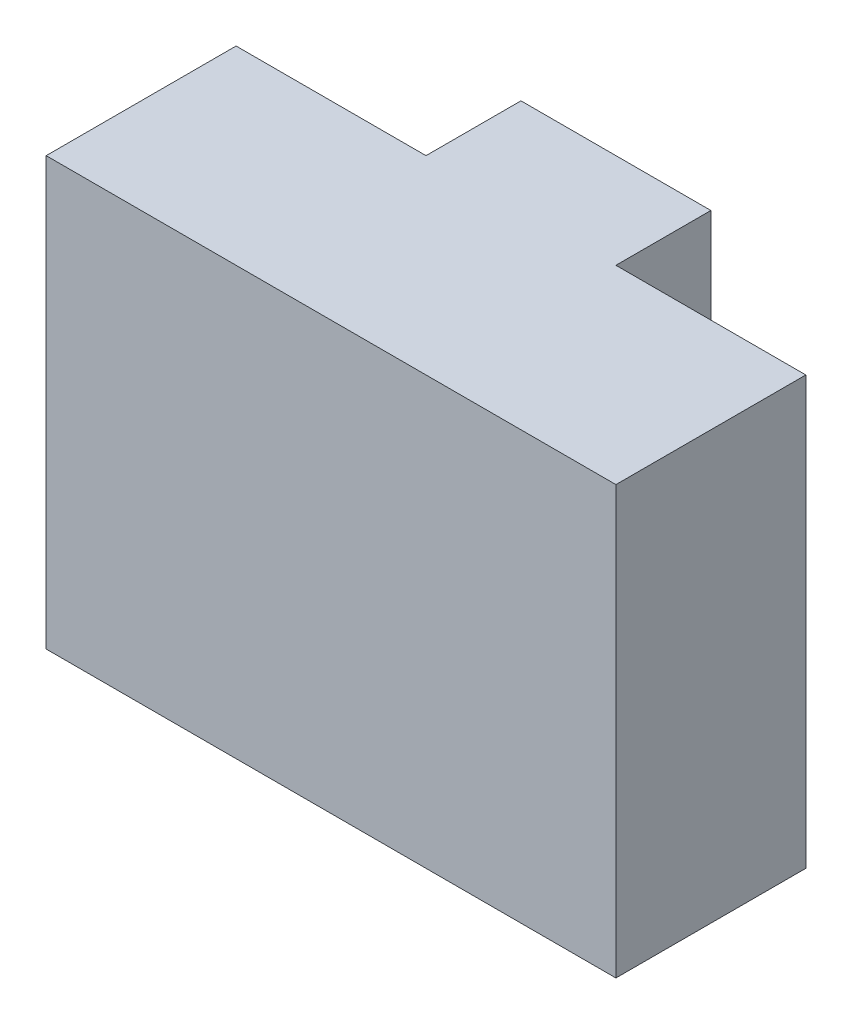
from build123d import *

# Parameters (mm, degrees)
BOSS_EXTRUDE1_DEPTH = 45


with BuildPart() as part:
    # Sketch1 → Boss-Extrude1 (new body)
    with BuildSketch(Plane(origin=(0, 0, 0), x_dir=(1, 0, 0), z_dir=(0, 1, 0))):
        Polygon((-30, 0), (30, 0), (30, 20), (10, 20), (10, 30), (-10, 30), (-10, 20), (-30, 20), align=None)
    extrude(amount=BOSS_EXTRUDE1_DEPTH)


solid = part.part
